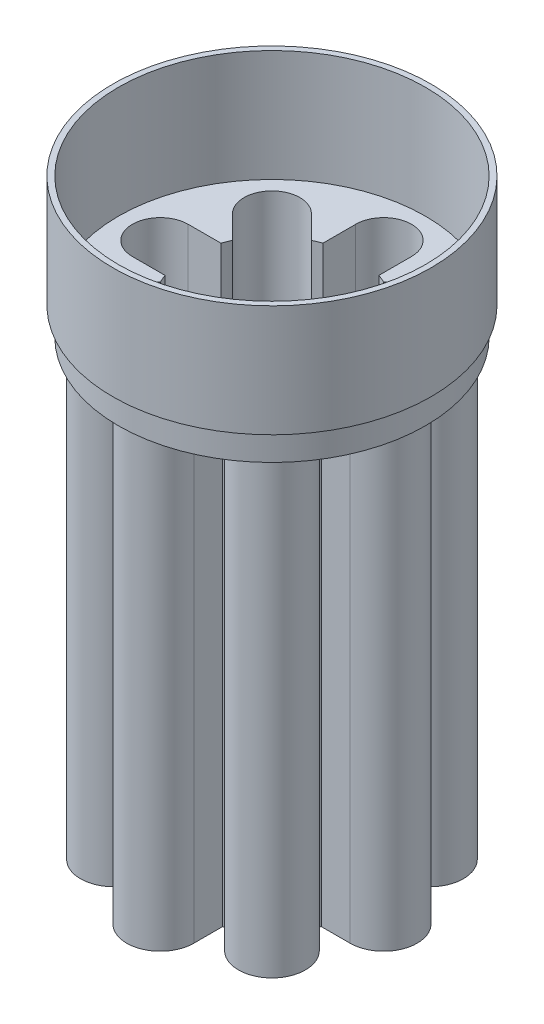
from build123d import *

# Parameters (mm, degrees)
EXTRUDE_THIN1_DEPTH = 80
BOSS_EXTRUDE1_DEPTH = 1
SKETCH3_R           = 27.5
BOSS_EXTRUDE2_DEPTH = 5
SKETCH4_R           = 28.5
SKETCH4_R_2         = 27.5
EXTRUDE_THIN2_DEPTH = 20


with BuildPart() as part:
    # Sketch1 → Extrude-Thin1 (new body)
    with BuildSketch(Plane(origin=(0, 0, 0), x_dir=(1, 0, 0), z_dir=(0, 1, 0))):
        with BuildLine():
            Line((-6.245447795, -14.730729169), (-9.899494937, -18.384776311))
            ThreePointArc((-9.899494937, -18.384776311), (-18.384776311, -18.384776311), (-18.384776311, -9.899494937))
            Line((-18.384776311, -9.899494937), (-14.730729169, -6.245447795))
            ThreePointArc((-14.730729169, -6.245447795), (-14.78207252, -6.122934918), (-14.832396974, -6))
            Line((-14.832396974, -6), (-20, -6))
            ThreePointArc((-20, -6), (-26, 0), (-20, 6))
            Line((-20, 6), (-14.832396974, 6))
            ThreePointArc((-14.832396974, 6), (-14.78207252, 6.122934918), (-14.730729169, 6.245447795))
            Line((-14.730729169, 6.245447795), (-18.384776311, 9.899494937))
            ThreePointArc((-18.384776311, 9.899494937), (-18.384776311, 18.384776311), (-9.899494937, 18.384776311))
            Line((-9.899494937, 18.384776311), (-6.245447795, 14.730729169))
            ThreePointArc((-6.245447795, 14.730729169), (-6.122934918, 14.78207252), (-6, 14.832396974))
            Line((-6, 14.832396974), (-6, 20))
            ThreePointArc((-6, 20), (0, 26), (6, 20))
            Line((6, 20), (6, 14.832396974))
            ThreePointArc((6, 14.832396974), (6.122934918, 14.78207252), (6.245447795, 14.730729169))
            Line((6.245447795, 14.730729169), (9.899494937, 18.384776311))
            ThreePointArc((9.899494937, 18.384776311), (18.384776311, 18.384776311), (18.384776311, 9.899494937))
            Line((18.384776311, 9.899494937), (14.730729169, 6.245447795))
            ThreePointArc((14.730729169, 6.245447795), (14.78207252, 6.122934918), (14.832396974, 6))
            Line((14.832396974, 6), (20, 6))
            ThreePointArc((20, 6), (26, 0), (20, -6))
            Line((20, -6), (14.832396974, -6))
            ThreePointArc((14.832396974, -6), (14.78207252, -6.122934918), (14.730729169, -6.245447795))
            Line((14.730729169, -6.245447795), (18.384776311, -9.899494937))
            ThreePointArc((18.384776311, -9.899494937), (18.384776311, -18.384776311), (9.899494937, -18.384776311))
            Line((9.899494937, -18.384776311), (6.245447795, -14.730729169))
            ThreePointArc((6.245447795, -14.730729169), (6.122934918, -14.78207252), (6, -14.832396974))
            Line((6, -14.832396974), (6, -20))
            ThreePointArc((6, -20), (0, -26), (-6, -20))
            Line((-6, -20), (-6, -14.832396974))
            ThreePointArc((-6, -14.832396974), (-6.122934918, -14.78207252), (-6.245447795, -14.730729169))
        make_face()
        with BuildLine():
            Line((-6.464466094, -13.535533906), (-10.606601718, -17.67766953))
            ThreePointArc((-10.606601718, -17.67766953), (-17.67766953, -17.67766953), (-17.67766953, -10.606601718))
            Line((-17.67766953, -10.606601718), (-13.535533906, -6.464466094))
            ThreePointArc((-13.535533906, -6.464466094), (-13.858192988, -5.740251485), (-14.142135624, -5))
            Line((-14.142135624, -5), (-20, -5))
            ThreePointArc((-20, -5), (-25, 0), (-20, 5))
            Line((-20, 5), (-14.142135624, 5))
            ThreePointArc((-14.142135624, 5), (-13.858192988, 5.740251485), (-13.535533906, 6.464466094))
            Line((-13.535533906, 6.464466094), (-17.67766953, 10.606601718))
            ThreePointArc((-17.67766953, 10.606601718), (-17.67766953, 17.67766953), (-10.606601718, 17.67766953))
            Line((-10.606601718, 17.67766953), (-6.464466094, 13.535533906))
            ThreePointArc((-6.464466094, 13.535533906), (-5.740251485, 13.858192988), (-5, 14.142135624))
            Line((-5, 14.142135624), (-5, 20))
            ThreePointArc((-5, 20), (0, 25), (5, 20))
            Line((5, 20), (5, 14.142135624))
            ThreePointArc((5, 14.142135624), (5.740251485, 13.858192988), (6.464466094, 13.535533906))
            Line((6.464466094, 13.535533906), (10.606601718, 17.67766953))
            ThreePointArc((10.606601718, 17.67766953), (17.67766953, 17.67766953), (17.67766953, 10.606601718))
            Line((17.67766953, 10.606601718), (13.535533906, 6.464466094))
            ThreePointArc((13.535533906, 6.464466094), (13.858192988, 5.740251485), (14.142135624, 5))
            Line((14.142135624, 5), (20, 5))
            ThreePointArc((20, 5), (25, 0), (20, -5))
            Line((20, -5), (14.142135624, -5))
            ThreePointArc((14.142135624, -5), (13.858192988, -5.740251485), (13.535533906, -6.464466094))
            Line((13.535533906, -6.464466094), (17.67766953, -10.606601718))
            ThreePointArc((17.67766953, -10.606601718), (17.67766953, -17.67766953), (10.606601718, -17.67766953))
            Line((10.606601718, -17.67766953), (6.464466094, -13.535533906))
            ThreePointArc((6.464466094, -13.535533906), (5.740251485, -13.858192988), (5, -14.142135624))
            Line((5, -14.142135624), (5, -20))
            ThreePointArc((5, -20), (0, -25), (-5, -20))
            Line((-5, -20), (-5, -14.142135624))
            ThreePointArc((-5, -14.142135624), (-5.740251485, -13.858192988), (-6.464466094, -13.535533906))
        make_face(mode=Mode.SUBTRACT)
    extrude(amount=EXTRUDE_THIN1_DEPTH)

    # Sketch2 → Boss-Extrude1 (add)
    with BuildSketch(Plane.XZ):
        with BuildLine():
            Line((14.730729169, 6.245447795), (18.384776311, 9.899494937))
            ThreePointArc((18.384776311, 9.899494937), (18.384776311, 18.384776311), (9.899494937, 18.384776311))
            Line((9.899494937, 18.384776311), (6.245447795, 14.730729169))
            ThreePointArc((6.245447795, 14.730729169), (6.122934918, 14.78207252), (6, 14.832396974))
            Line((6, 14.832396974), (6, 20))
            ThreePointArc((6, 20), (0, 26), (-6, 20))
            Line((-6, 20), (-6, 14.832396974))
            ThreePointArc((-6, 14.832396974), (-6.122934918, 14.78207252), (-6.245447795, 14.730729169))
            Line((-6.245447795, 14.730729169), (-9.899494937, 18.384776311))
            ThreePointArc((-9.899494937, 18.384776311), (-18.384776311, 18.384776311), (-18.384776311, 9.899494937))
            Line((-18.384776311, 9.899494937), (-14.730729169, 6.245447795))
            ThreePointArc((-14.730729169, 6.245447795), (-14.78207252, 6.122934918), (-14.832396974, 6))
            Line((-14.832396974, 6), (-20, 6))
            ThreePointArc((-20, 6), (-26, 0), (-20, -6))
            Line((-20, -6), (-14.832396974, -6))
            ThreePointArc((-14.832396974, -6), (-14.78207252, -6.122934918), (-14.730729169, -6.245447795))
            Line((-14.730729169, -6.245447795), (-18.384776311, -9.899494937))
            ThreePointArc((-18.384776311, -9.899494937), (-18.384776311, -18.384776311), (-9.899494937, -18.384776311))
            Line((-9.899494937, -18.384776311), (-6.245447795, -14.730729169))
            ThreePointArc((-6.245447795, -14.730729169), (-6.122934918, -14.78207252), (-6, -14.832396974))
            Line((-6, -14.832396974), (-6, -20))
            ThreePointArc((-6, -20), (0, -26), (6, -20))
            Line((6, -20), (6, -14.832396974))
            ThreePointArc((6, -14.832396974), (6.122934918, -14.78207252), (6.245447795, -14.730729169))
            Line((6.245447795, -14.730729169), (9.899494937, -18.384776311))
            ThreePointArc((9.899494937, -18.384776311), (18.384776311, -18.384776311), (18.384776311, -9.899494937))
            Line((18.384776311, -9.899494937), (14.730729169, -6.245447795))
            ThreePointArc((14.730729169, -6.245447795), (14.78207252, -6.122934918), (14.832396974, -6))
            Line((14.832396974, -6), (20, -6))
            ThreePointArc((20, -6), (26, 0), (20, 6))
            Line((20, 6), (14.832396974, 6))
            ThreePointArc((14.832396974, 6), (14.78207252, 6.122934918), (14.730729169, 6.245447795))
        make_face()
    extrude(amount=BOSS_EXTRUDE1_DEPTH)

    # Sketch3 → Boss-Extrude2 (add)
    with BuildSketch(Plane(origin=(0, 80, 0), x_dir=(1, 0, 0), z_dir=(0, 1, 0))):
        Circle(SKETCH3_R)
        with BuildLine():
            Line((-20, -5), (-14.142135624, -5))
            ThreePointArc((-14.142135624, -5), (-13.858192988, -5.740251485), (-13.535533906, -6.464466094))
            Line((-13.535533906, -6.464466094), (-17.67766953, -10.606601718))
            ThreePointArc((-17.67766953, -10.606601718), (-17.67766953, -17.67766953), (-10.606601718, -17.67766953))
            Line((-10.606601718, -17.67766953), (-6.464466094, -13.535533906))
            ThreePointArc((-6.464466094, -13.535533906), (-5.740251485, -13.858192988), (-5, -14.142135624))
            Line((-5, -14.142135624), (-5, -20))
            ThreePointArc((-5, -20), (0, -25), (5, -20))
            Line((5, -20), (5, -14.142135624))
            ThreePointArc((5, -14.142135624), (5.740251485, -13.858192988), (6.464466094, -13.535533906))
            Line((6.464466094, -13.535533906), (10.606601718, -17.67766953))
            ThreePointArc((10.606601718, -17.67766953), (17.67766953, -17.67766953), (17.67766953, -10.606601718))
            Line((17.67766953, -10.606601718), (13.535533906, -6.464466094))
            ThreePointArc((13.535533906, -6.464466094), (13.858192988, -5.740251485), (14.142135624, -5))
            Line((14.142135624, -5), (20, -5))
            ThreePointArc((20, -5), (25, 0), (20, 5))
            Line((20, 5), (14.142135624, 5))
            ThreePointArc((14.142135624, 5), (13.858192988, 5.740251485), (13.535533906, 6.464466094))
            Line((13.535533906, 6.464466094), (17.67766953, 10.606601718))
            ThreePointArc((17.67766953, 10.606601718), (17.67766953, 17.67766953), (10.606601718, 17.67766953))
            Line((10.606601718, 17.67766953), (6.464466094, 13.535533906))
            ThreePointArc((6.464466094, 13.535533906), (5.740251485, 13.858192988), (5, 14.142135624))
            Line((5, 14.142135624), (5, 20))
            ThreePointArc((5, 20), (0, 25), (-5, 20))
            Line((-5, 20), (-5, 14.142135624))
            ThreePointArc((-5, 14.142135624), (-5.740251485, 13.858192988), (-6.464466094, 13.535533906))
            Line((-6.464466094, 13.535533906), (-10.606601718, 17.67766953))
            ThreePointArc((-10.606601718, 17.67766953), (-17.67766953, 17.67766953), (-17.67766953, 10.606601718))
            Line((-17.67766953, 10.606601718), (-13.535533906, 6.464466094))
            ThreePointArc((-13.535533906, 6.464466094), (-13.858192988, 5.740251485), (-14.142135624, 5))
            Line((-14.142135624, 5), (-20, 5))
            ThreePointArc((-20, 5), (-25, 0), (-20, -5))
        make_face(mode=Mode.SUBTRACT)
    extrude(amount=BOSS_EXTRUDE2_DEPTH)


with BuildPart() as body_2:
    # Sketch4 → Extrude-Thin2 (new body)
    with BuildSketch(Plane(origin=(0, 85, 0), x_dir=(1, 0, 0), z_dir=(0, 1, 0))):
        Circle(SKETCH4_R)
        Circle(SKETCH4_R_2, mode=Mode.SUBTRACT)
    extrude(amount=EXTRUDE_THIN2_DEPTH)


solid = Compound([part.part, body_2.part])
